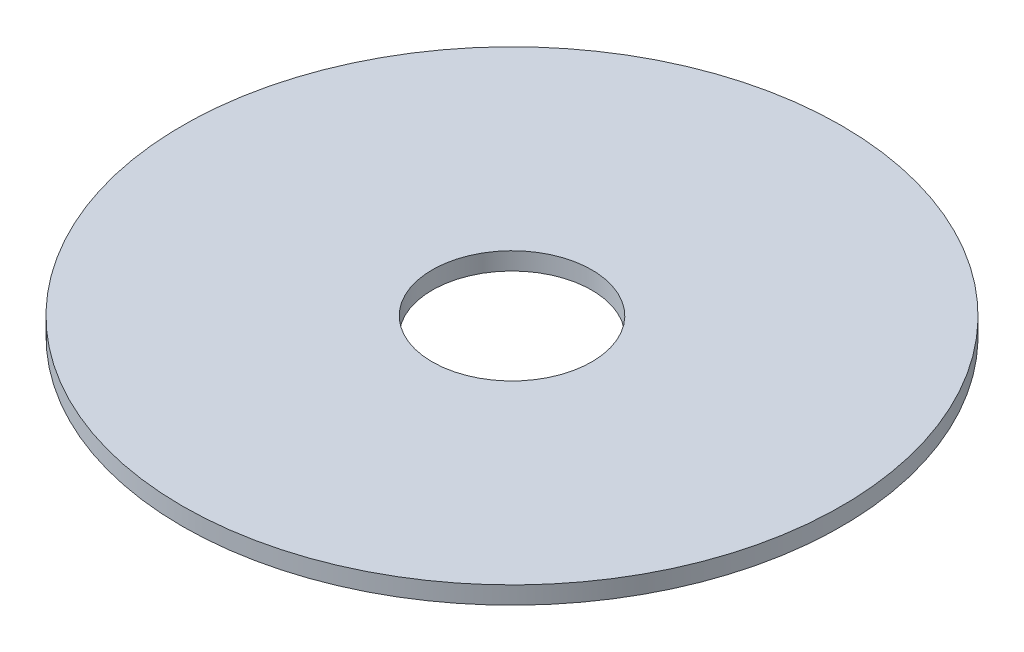
from build123d import *

# Parameters (mm, degrees)
SKETCH1_R           = 93.696187323
SKETCH1_R_2         = 22.684007712
BOSS_EXTRUDE1_DEPTH = 2
SKETCH1_3_R         = 93.696187323
SKETCH1_3_R_2       = 22.684007712
BOSS_EXTRUDE2_DEPTH = 5


with BuildPart() as part:
    # Sketch1 → Boss-Extrude1 (new body)
    with BuildSketch(Plane(origin=(0, 0, 0), x_dir=(1, 0, 0), z_dir=(0, 1, 0))):
        Circle(SKETCH1_R)
        Circle(SKETCH1_R_2, mode=Mode.SUBTRACT)
    extrude(amount=BOSS_EXTRUDE1_DEPTH)

    # Sketch1_3 → Boss-Extrude2 (add)
    with BuildSketch(Plane(origin=(0, 0, 0), x_dir=(1, 0, 0), z_dir=(0, 1, 0))):
        Circle(SKETCH1_3_R)
        Circle(SKETCH1_3_R_2, mode=Mode.SUBTRACT)
    extrude(amount=BOSS_EXTRUDE2_DEPTH)


solid = part.part
